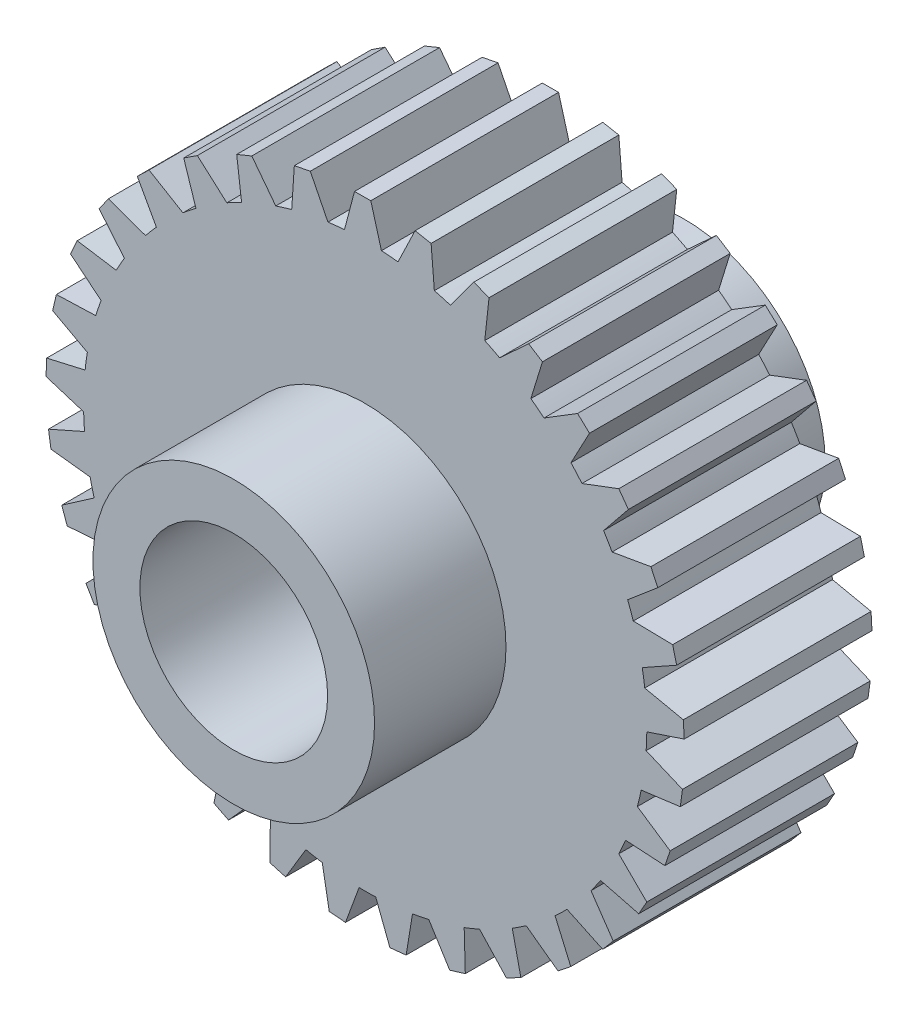
from build123d import *

# Parameters (mm, degrees)
BOSS_EXTRUDE1_DEPTH     = 5
SKETCH2_R               = 7.5
BOSS_EXTRUDE2_DEPTH     = 7
SKETCH3_R               = 5
CUT_EXTRUDE1_DEPTH      = 1
CUT_EXTRUDE1_DEPTH_BACK = 25


with BuildPart() as part:
    # Sketch1 → Boss-Extrude1 (new body, symmetric)
    with BuildSketch(Plane.XY):
        with BuildLine():
            Line((-1.102638188, 14.959418071), (-0.56896822, 16.990476013))
            Line((-0.56896822, 16.990476013), (0.299469927, 16.997362082))
            Line((0.299469927, 16.997362082), (0.865280327, 14.975022202))
            ThreePointArc((0.865280327, 14.975022202), (1.307399264, 14.942914949), (1.748376405, 14.897757548))
            Line((1.748376405, 14.897757548), (2.656782505, 16.791113921))
            Line((2.656782505, 16.791113921), (3.51083004, 16.63352255))
            Line((3.51083004, 16.63352255), (3.68368517, 14.540648664))
            ThreePointArc((3.68368517, 14.540648664), (4.111738104, 14.425450071), (4.53620012, 14.29765325))
            Line((4.53620012, 14.29765325), (5.786510188, 15.984877223))
            Line((5.786510188, 15.984877223), (6.595299608, 15.668504175))
            Line((6.595299608, 15.668504175), (6.368952034, 13.580738198))
            ThreePointArc((6.368952034, 13.580738198), (6.767468017, 13.386611843), (7.160073744, 13.180794513))
            Line((7.160073744, 13.180794513), (8.707098316, 14.600905414))
            Line((8.707098316, 14.600905414), (9.441397865, 14.137185235))
            Line((9.441397865, 14.137185235), (8.824028377, 12.129984469))
            ThreePointArc((8.824028377, 12.129984469), (9.178604003, 11.863946585), (9.525163646, 11.587547519))
            Line((9.525163646, 11.587547519), (11.312989225, 12.689218841))
            Line((11.312989225, 12.689218841), (11.946259403, 12.094911586))
            Line((11.946259403, 12.094911586), (10.960181343, 10.240821497))
            ThreePointArc((10.960181343, 10.240821497), (11.258001325, 9.912487385), (11.545989318, 9.575496367))
            Line((11.545989318, 9.575496367), (13.509999227, 10.318910838))
            Line((13.509999227, 10.318910838), (14.019352001, 9.61549632))
            Line((14.019352001, 9.61549632), (12.7002048, 7.981528553))
            ThreePointArc((12.7002048, 7.981528553), (12.930505147, 7.602765065), (13.149512852, 7.217361828))
            Line((13.149512852, 7.217361828), (15.218722658, 7.575650511))
            Line((15.218722658, 7.575650511), (15.58574869, 6.788551963))
            Line((15.58574869, 6.788551963), (13.981209764, 5.433762373))
            ThreePointArc((13.981209764, 5.433762373), (14.135666823, 5.018259007), (14.277778731, 4.598373027))
            Line((14.277778731, 4.598373027), (16.377401799, 4.558586437))
            Line((16.377401799, 4.558586437), (16.588835814, 3.716251652))
            Line((16.588835814, 3.716251652), (14.756897381, 2.689605862))
            ThreePointArc((14.756897381, 2.689605862), (14.82992867, 2.252379993), (14.890008487, 1.813187044))
            Line((14.890008487, 1.813187044), (16.944158969, 1.376763172))
            Line((16.944158969, 1.376763172), (16.992359189, 0.509636323))
            Line((16.992359189, 0.509636323), (14.999232277, -0.151760012))
            ThreePointArc((14.999232277, -0.151760012), (14.988198256, -0.594905903), (14.96407454, -1.037532242))
            Line((14.96407454, -1.037532242), (16.898510086, -1.854819902))
            Line((16.898510086, -1.854819902), (16.78173443, -2.715398591))
            Line((16.78173443, -2.715398591), (14.699455839, -2.987640883))
            ThreePointArc((14.699455839, -2.987640883), (14.604755306, -3.420690349), (14.497299951, -3.85075241))
            Line((14.497299951, -3.85075241), (16.24210502, -5.019364952))
            Line((16.24210502, -5.019364952), (15.964574065, -5.842291924))
            Line((15.964574065, -5.842291924), (13.868402767, -5.715540629))
            ThreePointArc((13.868402767, -5.715540629), (13.693458446, -6.122842133), (13.506555169, -6.524796354))
            Line((13.506555169, -6.524796354), (14.99866796, -8.002497074))
            Line((14.99866796, -8.002497074), (14.570412397, -8.758029606))
            Line((14.570412397, -8.758029606), (12.536109486, -8.236865845))
            ThreePointArc((12.536109486, -8.236865845), (12.28724432, -8.60369845), (12.027648293, -8.963017156))
            Line((12.027648293, -8.963017156), (13.213139961, -10.696398102))
            Line((13.213139961, -10.696398102), (12.649638063, -11.357229278))
            Line((12.649638063, -11.357229278), (10.750728545, -10.460489269))
            ThreePointArc((10.750728545, -10.460489269), (10.436937171, -10.773594688), (10.114030869, -11.077291166))
            Line((10.114030869, -11.077291166), (10.950054658, -13.003703433))
            Line((10.950054658, -13.003703433), (10.271672851, -13.545949094))
            Line((10.271672851, -13.545949094), (8.576788264, -12.306043355))
            ThreePointArc((8.576788264, -12.306043355), (8.209411919, -12.554105143), (7.834866018, -12.791203011))
            Line((7.834866018, -12.791203011), (8.291205849, -14.841021042))
            Line((8.291205849, -14.841021042), (7.522462619, -15.245083015))
            Line((7.522462619, -15.245083015), (6.092860509, -13.706824972))
            ThreePointArc((6.092860509, -13.706824972), (5.68517713, -13.88087753), (5.272528696, -14.042807453))
            Line((5.272528696, -14.042807453), (5.332691259, -16.141945482))
            Line((5.332691259, -16.141945482), (4.501370988, -16.393219916))
            Line((4.501370988, -16.393219916), (3.3887209, -14.612206222))
            ThreePointArc((3.3887209, -14.612206222), (2.955465228, -14.705958836), (2.519628449, -14.786868244))
            Line((2.519628449, -14.786868244), (2.181439312, -16.859457955))
            Line((2.181439312, -16.859457955), (1.317588082, -16.948863137))
            Line((1.317588082, -16.948863137), (0.562104089, -14.989464266))
            ThreePointArc((0.562104089, -14.989464266), (0.118935112, -14.999528474), (-0.324337735, -14.996493091))
            Line((-0.324337735, -14.996493091), (-1.048655536, -16.96762569))
            Line((-1.048655536, -16.96762569), (-1.91381589, -16.891930285))
            Line((-1.91381589, -16.891930285), (-2.284828629, -14.824964018))
            ThreePointArc((-2.284828629, -14.824964018), (-2.721893629, -14.750976072), (-3.156581508, -14.664105605))
            Line((-3.156581508, -14.664105605), (-4.24084924, -16.462539225))
            Line((-4.24084924, -16.462539225), (-5.07604957, -16.22447906))
            Line((-5.07604957, -16.22447906), (-5.049181687, -14.124650944))
            ThreePointArc((-5.049181687, -14.124650944), (-5.464346042, -13.969284961), (-5.874738201, -13.801719134))
            Line((-5.874738201, -13.801719134), (-7.279767603, -15.362453699))
            Line((-7.279767603, -15.362453699), (-8.054821592, -14.97063289))
            Line((-8.054821592, -14.97063289), (-7.631044164, -12.913836183))
            ThreePointArc((-7.631044164, -12.913836183), (-8.009302753, -12.682707496), (-8.380566549, -12.440502575))
            Line((-8.380566549, -12.440502575), (-10.055576198, -13.70712907))
            Line((-10.055576198, -13.70712907), (-10.742471376, -13.175709041))
            Line((-10.742471376, -13.175709041), (-9.937100822, -11.236281736))
            ThreePointArc((-9.937100822, -11.236281736), (-10.264782393, -10.937743936), (-10.583499387, -10.629653839))
            Line((-10.583499387, -10.629653839), (-12.467950069, -11.556393082))
            Line((-12.467950069, -11.556393082), (-13.041860255, -10.904580739))
            Line((-13.041860255, -10.904580739), (-11.884004765, -9.152618792))
            ThreePointArc((-11.884004765, -9.152618792), (-12.149266054, -8.797461813), (-12.403916981, -8.434621718))
            Line((-12.403916981, -8.434621718), (-14.42969974, -8.987978939))
            Line((-14.42969974, -8.987978939), (-14.869882324, -8.239332477))
            Line((-14.869882324, -8.239332477), (-13.401389813, -6.738156357))
            ThreePointArc((-13.401389813, -6.738156357), (-13.594643584, -6.339216499), (-13.776024698, -5.934740391))
            Line((-13.776024698, -5.934740391), (-15.869922466, -6.094715819))
            Line((-15.869922466, -6.094715819), (-16.160468103, -5.276293272))
            Line((-16.160468103, -5.276293272), (-14.434413716, -4.080159395))
            ThreePointArc((-14.434413716, -4.080159395), (-14.548675275, -3.651855384), (-14.650230989, -3.220362085))
            Line((-14.650230989, -3.220362085), (-16.736564846, -2.98117379))
            Line((-16.736564846, -2.98117379), (-16.866972459, -2.122555081))
            Line((-16.866972459, -2.122555081), (-14.945740298, -1.274694842))
            ThreePointArc((-14.945740298, -1.274694842), (-14.976879935, -0.8325067), (-14.994939762, -0.389591502))
            Line((-14.994939762, -0.389591502), (-16.998304165, 0.240115627))
            Line((-16.998304165, 0.240115627), (-16.963860484, 1.107897781))
            Line((-16.963860484, 1.107897781), (-14.916888886, 1.576840503))
            ThreePointArc((-14.916888886, 1.576840503), (-14.863781133, 2.016930945), (-14.797692342, 2.455259933))
            Line((-14.797692342, 2.455259933), (-16.645680483, 3.45272664))
            Line((-16.645680483, 3.45272664), (-16.447630392, 4.29830833))
            Line((-16.447630392, 4.29830833), (-14.348902243, 4.371384725))
            ThreePointArc((-14.348902243, 4.371384725), (-14.213466553, 4.793471451), (-14.065617767, 5.211371877))
            Line((-14.065617767, 5.211371877), (-15.691438539, 6.540547117))
            Line((-15.691438539, 6.540547117), (-15.336940083, 7.333366818))
            Line((-15.336940083, 7.333366818), (-13.262308888, 7.007935713))
            ThreePointArc((-13.262308888, 7.007935713), (-13.049440259, 7.396763409), (-12.825175117, 7.779131264))
            Line((-12.825175117, 7.779131264), (-14.170067122, 9.391975179))
            Line((-14.170067122, 9.391975179), (-13.6719328, 10.103378321))
            Line((-13.6719328, 10.103378321), (-11.696381135, 9.391201645))
            ThreePointArc((-11.696381135, 9.391201645), (-11.413773194, 9.732717065), (-11.121197223, 10.065732577))
            Line((-11.121197223, 10.065732577), (-12.136552559, 11.903952788))
            Line((-12.136552559, 11.903952788), (-11.512786244, 12.508227408))
            Line((-11.512786244, 12.508227408), (-9.707715693, 11.435045082))
            ThreePointArc((-9.707715693, 11.435045082), (-9.365582628, 11.716904968), (-9.015270286, 11.98853209))
            Line((-9.015270286, 11.98853209), (-9.664391366, 13.985690527))
            Line((-9.664391366, 13.985690527), (-8.937537597, 14.460996567))
            Line((-8.937537597, 14.460996567), (-7.368188113, 13.065596195))
            ThreePointArc((-7.368188113, 13.065596195), (-6.978895504, 13.277613398), (-6.583507991, 13.478034817))
            Line((-6.583507991, 13.478034817), (-6.842933888, 15.561948972))
            Line((-6.842933888, 15.561948972), (-6.039263054, 15.891107632))
            Line((-6.039263054, 15.891107632), (-4.762355017, 14.22392262))
            ThreePointArc((-4.762355017, 14.22392262), (-4.339972912, 14.358434285), (-3.913800564, 14.480406249))
            Line((-3.913800564, 14.480406249), (-3.774154951, 16.575758034))
            Line((-3.774154951, 16.575758034), (-2.92271381, 16.746872663))
            Line((-2.92271381, 16.746872663), (-1.984398002, 14.868159421))
            ThreePointArc((-1.984398002, 14.868159421), (-1.544192393, 14.920303946), (-1.102638188, 14.959418071))
        make_face()
    extrude(amount=BOSS_EXTRUDE1_DEPTH, both=True)

    # Sketch2 → Boss-Extrude2 (add)
    with BuildSketch(Plane.XY.offset(5)):
        Circle(SKETCH2_R)
    boss_extrude2 = extrude(amount=BOSS_EXTRUDE2_DEPTH)

    # Mirror1: Boss-Extrude2 across plane
    add(boss_extrude2.mirror(Plane.XY))

    # Sketch3 → Cut-Extrude1 (cut, two sides)
    with BuildSketch(Plane.XY.offset(12)) as cut_extrude1_sk:
        Circle(SKETCH3_R)
    extrude(amount=CUT_EXTRUDE1_DEPTH, mode=Mode.SUBTRACT)
    extrude(cut_extrude1_sk.sketch, amount=-CUT_EXTRUDE1_DEPTH_BACK, mode=Mode.SUBTRACT)


solid = part.part
